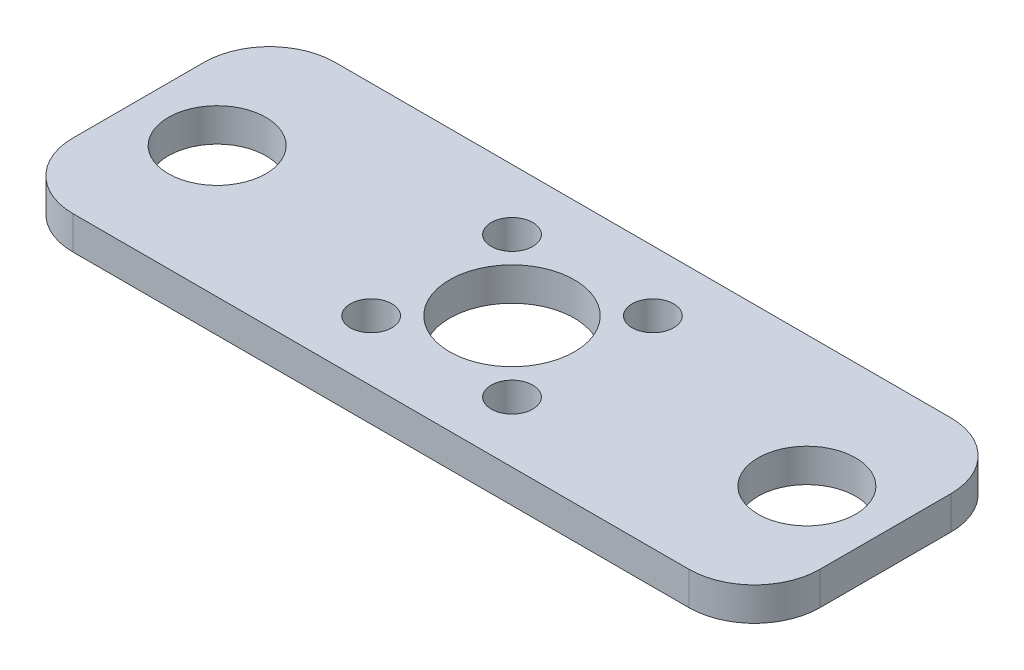
from build123d import *

# Parameters (mm, degrees)
SKETCH1_W           = 114
SKETCH1_H           = 40
SKETCH1_R           = 7.45
SKETCH1_R_2         = 9.525
BOSS_EXTRUDE1_DEPTH = 5.08
FILLET1_R           = 10
SKETCH2_R           = 3.175
CUT_EXTRUDE1_DEPTH  = 6.08


with BuildPart() as part:
    # Sketch1 → Boss-Extrude1 (new body)
    with BuildSketch(Plane(origin=(0, 0, 0), x_dir=(1, 0, 0), z_dir=(0, 1, 0))):
        Rectangle(SKETCH1_W, SKETCH1_H)
        with Locations((-45, 0)):
            Circle(SKETCH1_R, mode=Mode.SUBTRACT)
        with Locations((45, 0)):
            Circle(SKETCH1_R, mode=Mode.SUBTRACT)
        Circle(SKETCH1_R_2, mode=Mode.SUBTRACT)
    extrude(amount=BOSS_EXTRUDE1_DEPTH)

    # Fillet1
    fillet1_edges = [part.edges().sort_by_distance(p)[0] for p in [
        (-57, 2.54, -20),
        (57, 2.54, -20),
        (57, 2.54, 20),
        (-57, 2.54, 20),
    ]]
    fillet(fillet1_edges, radius=FILLET1_R)

    # Sketch2 → Cut-Extrude1 (cut, through all)
    with BuildSketch(Plane(origin=(0, 5.08, 0), x_dir=(1, 0, 0), z_dir=(0, 1, 0))):
        with Locations((-10.75, -10.75)):
            Circle(SKETCH2_R)
        with Locations((-10.75, 10.75)):
            Circle(SKETCH2_R)
        with Locations((10.75, 10.75)):
            Circle(SKETCH2_R)
        with Locations((10.75, -10.75)):
            Circle(SKETCH2_R)
    extrude(amount=-CUT_EXTRUDE1_DEPTH, mode=Mode.SUBTRACT)


solid = part.part
